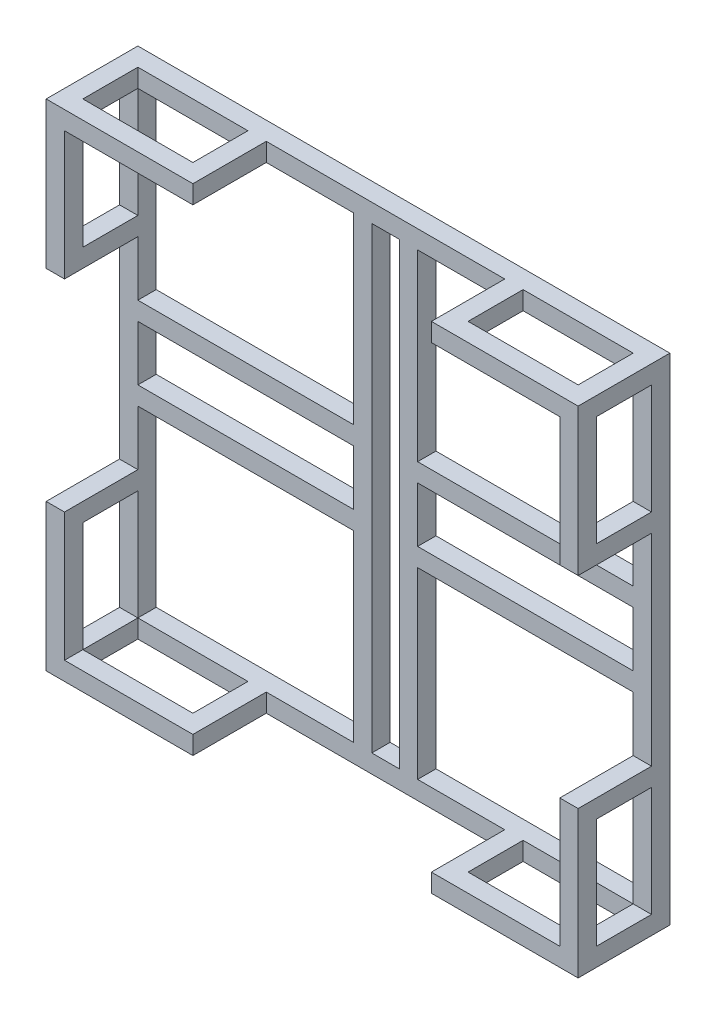
from build123d import *

# Parameters (mm, degrees)
SKETCH_1_W                       = 580
SKETCH_1_H                       = 540
EXTRUDE_1_DEPTH                  = 100
SHELL_1_T                        = -20
SKETCH_2_W                       = 235
SKETCH_2_H                       = 200
CUT_EXTRUDE_1_DEPTH              = 43
PATTERN_LINEAR_1_COUNT           = 2
PATTERN_LINEAR_1_PITCH           = 305
PATTERN_LINEAR_2_COUNT           = 2
PATTERN_LINEAR_2_PITCH           = 300
PATTERN_LINEAR_3_COPY_1_SKETCH_W = 235
PATTERN_LINEAR_3_COPY_1_SKETCH_H = 200
PATTERN_LINEAR_3_COPY_1_DEPTH    = 43
PATTERN_LINEAR_3_COPY_2_SKETCH_W = 235
PATTERN_LINEAR_3_COPY_2_SKETCH_H = 200
PATTERN_LINEAR_3_COPY_2_DEPTH    = 43
SKETCH_4_W                       = 260
SKETCH_4_H                       = 80
CUT_EXTRUDE_2_DEPTH              = 549
SKETCH_6_W                       = 80
SKETCH_6_H                       = 220
CUT_EXTRUDE_3_DEPTH              = 614
SKETCH_8_W                       = 120
SKETCH_8_H                       = 60
CUT_EXTRUDE_4_DEPTH              = 614
SKETCH_10_W                      = 120
SKETCH_10_H                      = 60
CUT_EXTRUDE_5_DEPTH              = 614
SKETCH_12_W                      = 60
SKETCH_12_H                      = 120
CUT_EXTRUDE_6_DEPTH              = 602
SKETCH_13_W                      = 60
SKETCH_13_H                      = 120
CUT_EXTRUDE_7_DEPTH              = 602
SKETCH_15_W                      = 30
SKETCH_15_H                      = 500
CUT_EXTRUDE_8_DEPTH              = 66
SKETCH_18_W                      = 235
SKETCH_18_H                      = 60
CUT_EXTRUDE_11_DEPTH             = 41
SKETCH_21_W                      = 235
SKETCH_21_H                      = 60
CUT_EXTRUDE_13_DEPTH             = 72


with BuildPart() as part:
    # 草图1 → 凸台-拉伸1 (new body)
    with BuildSketch(Plane.XY):
        with Locations((290, 270)):
            Rectangle(SKETCH_1_W, SKETCH_1_H)
    extrude(amount=EXTRUDE_1_DEPTH)

    # 抽壳1
    shell_1_openings = [part.faces().sort_by_distance(p)[0] for p in [
        (290, 270, 100),
    ]]
    offset(amount=SHELL_1_T, openings=shell_1_openings, kind=Kind.INTERSECTION)

    # 草图2 → 切除-拉伸1 (cut)
    with BuildSketch(Plane.XY.offset(20)):
        with Locations((442.5, 120)):
            Rectangle(SKETCH_2_W, SKETCH_2_H)
    cut_extrude_1 = extrude(amount=-CUT_EXTRUDE_1_DEPTH, mode=Mode.SUBTRACT)

    # 阵列(线性)1: 切除-拉伸1 ×2
    with Locations(*[(-i * PATTERN_LINEAR_1_PITCH, 0, 0) for i in range(1, PATTERN_LINEAR_1_COUNT)]):
        add(cut_extrude_1, mode=Mode.SUBTRACT)

    # 阵列(线性)2: 切除-拉伸1 ×2
    with Locations(*[(0, i * PATTERN_LINEAR_2_PITCH, 0) for i in range(1, PATTERN_LINEAR_2_COUNT)]):
        add(cut_extrude_1, mode=Mode.SUBTRACT)

    # 阵列(线性)3 copy 1 sketch → 阵列(线性)3 copy 1 (cut)
    with BuildSketch(Plane(origin=(-305, 300, 20), x_dir=(1, 0, 0), z_dir=(0, 0, 1))):
        with Locations((442.5, 120)):
            Rectangle(PATTERN_LINEAR_3_COPY_1_SKETCH_W, PATTERN_LINEAR_3_COPY_1_SKETCH_H)
    extrude(amount=-PATTERN_LINEAR_3_COPY_1_DEPTH, mode=Mode.SUBTRACT)

    # 阵列(线性)3 copy 2 sketch → 阵列(线性)3 copy 2 (cut)
    with BuildSketch(Plane(origin=(0, 300, 20), x_dir=(1, 0, 0), z_dir=(0, 0, 1))):
        with Locations((442.5, 120)):
            Rectangle(PATTERN_LINEAR_3_COPY_2_SKETCH_W, PATTERN_LINEAR_3_COPY_2_SKETCH_H)
    extrude(amount=-PATTERN_LINEAR_3_COPY_2_DEPTH, mode=Mode.SUBTRACT)

    # 草图4 → 切除-拉伸2 (cut)
    with BuildSketch(Plane.XZ):
        with Locations((290, 60)):
            Rectangle(SKETCH_4_W, SKETCH_4_H)
    extrude(amount=-CUT_EXTRUDE_2_DEPTH, mode=Mode.SUBTRACT)

    # 草图6 → 切除-拉伸3 (cut)
    with BuildSketch(Plane(origin=(580, 0, 0), x_dir=(0, 0, -1), z_dir=(1, 0, 0))):
        with Locations((-60, 270)):
            Rectangle(SKETCH_6_W, SKETCH_6_H)
    extrude(amount=-CUT_EXTRUDE_3_DEPTH, mode=Mode.SUBTRACT)

    # 草图8 → 切除-拉伸4 (cut)
    with BuildSketch(Plane.XZ):
        with Locations((80, 50)):
            Rectangle(SKETCH_8_W, SKETCH_8_H)
    extrude(amount=-CUT_EXTRUDE_4_DEPTH, mode=Mode.SUBTRACT)

    # 草图10 → 切除-拉伸5 (cut)
    with BuildSketch(Plane.XZ):
        with Locations((500, 50)):
            Rectangle(SKETCH_10_W, SKETCH_10_H)
    extrude(amount=-CUT_EXTRUDE_5_DEPTH, mode=Mode.SUBTRACT)

    # 草图12 → 切除-拉伸6 (cut)
    with BuildSketch(Plane(origin=(580, 0, 0), x_dir=(0, 0, -1), z_dir=(1, 0, 0))):
        with Locations((-50, 460)):
            Rectangle(SKETCH_12_W, SKETCH_12_H)
    extrude(amount=-CUT_EXTRUDE_6_DEPTH, mode=Mode.SUBTRACT)

    # 草图13 → 切除-拉伸7 (cut)
    with BuildSketch(Plane(origin=(580, 0, 0), x_dir=(0, 0, -1), z_dir=(1, 0, 0))):
        with Locations((-50, 80)):
            Rectangle(SKETCH_13_W, SKETCH_13_H)
    extrude(amount=-CUT_EXTRUDE_7_DEPTH, mode=Mode.SUBTRACT)

    # 草图15 → 切除-拉伸8 (cut)
    with BuildSketch(Plane.XY.offset(20)):
        with Locations((290, 270)):
            Rectangle(SKETCH_15_W, SKETCH_15_H)
    extrude(amount=-CUT_EXTRUDE_8_DEPTH, mode=Mode.SUBTRACT)

    # 草图18 → 切除-拉伸11 (cut)
    with BuildSketch(Plane.XY.offset(20)):
        with Locations((137.5, 270)):
            Rectangle(SKETCH_18_W, SKETCH_18_H)
    extrude(amount=-CUT_EXTRUDE_11_DEPTH, mode=Mode.SUBTRACT)

    # 草图21 → 切除-拉伸13 (cut)
    with BuildSketch(Plane.XY.offset(20)):
        with Locations((442.5, 270)):
            Rectangle(SKETCH_21_W, SKETCH_21_H)
    extrude(amount=-CUT_EXTRUDE_13_DEPTH, mode=Mode.SUBTRACT)


solid = part.part
